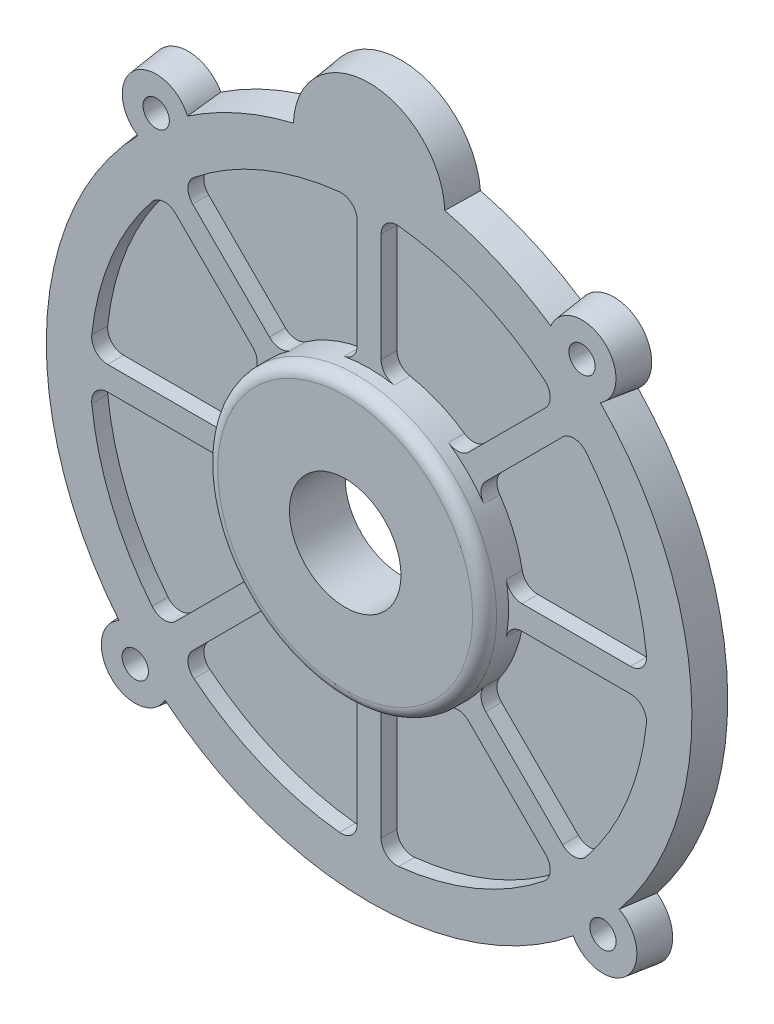
from build123d import *

# Parameters (mm, degrees)
BOSS_EXTRUDE1_START        = -4
BOSS_EXTRUDE1_DEPTH        = 4
BOSS_EXTRUDE1_DRAFT        = 7
CUT_EXTRUDE1_DEPTH         = 2
FILLET1_R                  = 2
CIRPATTERN1_COUNT          = 8
FILLET1_OF_CIRPATTERN1_R   = 2
M4X0_7_TAPPED_HOLE1_D      = 3.3
SKETCH9_R                  = 17.5
BOSS_EXTRUDE2_DEPTH        = 3
FILLET2_R                  = 1.5
F_14_0_14_DIAMETER_HOLE1_D = 14


with BuildPart() as part:
    # Sketch2 → Boss-Extrude1 (with draft: the straight prism first)
    with BuildSketch(Plane.XY.offset(BOSS_EXTRUDE1_START)):
        with BuildLine():
            ThreePointArc((-22.599988577, 34.208778352), (-29.7710089, 35.479706812), (-29.76462331, 28.19693599))
            ThreePointArc((-29.76462331, 28.19693599), (-40.960735586, 1.79391757), (-32.115758696, -25.486820975))
            ThreePointArc((-32.115758696, -25.486820975), (-32.70368863, -32.70368863), (-25.486820975, -32.115758696))
            ThreePointArc((-25.486820975, -32.115758696), (0, -41), (25.486820975, -32.115758696))
            ThreePointArc((25.486820975, -32.115758696), (32.70368863, -32.70368863), (32.115758696, -25.486820975))
            ThreePointArc((32.115758696, -25.486820975), (40.960735586, 1.79391757), (29.76462331, 28.19693599))
            ThreePointArc((29.76462331, 28.19693599), (29.7710089, 35.479706812), (22.599988577, 34.208778352))
            ThreePointArc((22.599988577, 34.208778352), (16.520796809, 37.524169182), (9.970370305, 39.769230769))
            ThreePointArc((9.970370305, 39.769230769), (0, 49), (-9.970370305, 39.769230769))
            ThreePointArc((-9.970370305, 39.769230769), (-16.520796809, 37.524169182), (-22.599988577, 34.208778352))
        make_face()
    extrude(amount=BOSS_EXTRUDE1_DEPTH)
    # Boss-Extrude1: the draft: its side faces are tilted about the plane it starts from
    boss_extrude1_sides = [part.faces().sort_by_distance(p)[0] for p in [
        (-16.520796809, 37.524169182, -2),
        (-29.7710089, 35.479706812, -2),
        (-40.960735586, 1.79391757, -2),
        (-32.70368863, -32.70368863, -2),
        (0, -41, -2),
        (32.70368863, -32.70368863, -2),
        (40.960735586, 1.79391757, -2),
        (29.7710089, 35.479706812, -2),
        (16.520796809, 37.524169182, -2),
        (0, 49, -2),
    ]]
    draft(boss_extrude1_sides, Plane.XY.offset(BOSS_EXTRUDE1_START), BOSS_EXTRUDE1_DRAFT)

    # Sketch4 → Cut-Extrude1 (cut)
    with BuildSketch(Plane.XY):
        with BuildLine():
            Line((-13.389488178, -11.268167834), (-25.786658635, -23.665338291))
            ThreePointArc((-25.786658635, -23.665338291), (-32.335783638, -13.393920133), (-34.96784237, -1.5))
            Line((-34.96784237, -1.5), (-17.435595774, -1.5))
            ThreePointArc((-17.435595774, -1.5), (-16.167891819, -6.696960066), (-13.389488178, -11.268167834))
        make_face()
    cut_extrude1 = extrude(amount=-CUT_EXTRUDE1_DEPTH, mode=Mode.SUBTRACT)

    # Fillet1
    fillet1_edges = [part.edges().sort_by_distance(p)[0] for p in [
        (-17.435595774, -1.5, -1),
        (-13.389488178, -11.268167834, -1),
        (-25.786658635, -23.665338291, -1),
        (-34.96784237, -1.5, -1),
    ]]
    fillet(fillet1_edges, radius=FILLET1_R)

    # CirPattern1: Cut-Extrude1 ×8 about axis
    cirpattern1_axis = Axis((0, 0, 0), (0, 0, 1))
    for i in range(1, CIRPATTERN1_COUNT):
        add(cut_extrude1.rotate(cirpattern1_axis, i * 360 / CIRPATTERN1_COUNT), mode=Mode.SUBTRACT)

    # Fillet1 of CirPattern1
    fillet1_of_cirpattern1_edges = [part.edges().sort_by_distance(p)[0] for p in [
        (-11.268167834, -13.389488178, -1),
        (-1.5, -17.435595774, -1),
        (-1.5, -34.96784237, -1),
        (-23.665338291, -25.786658635, -1),
        (1.5, -17.435595774, -1),
        (11.268167834, -13.389488178, -1),
        (23.665338291, -25.786658635, -1),
        (1.5, -34.96784237, -1),
        (13.389488178, -11.268167834, -1),
        (17.435595774, -1.5, -1),
        (34.96784237, -1.5, -1),
        (25.786658635, -23.665338291, -1),
        (17.435595774, 1.5, -1),
        (13.389488178, 11.268167834, -1),
        (25.786658635, 23.665338291, -1),
        (34.96784237, 1.5, -1),
        (11.268167834, 13.389488178, -1),
        (1.5, 17.435595774, -1),
        (1.5, 34.96784237, -1),
        (23.665338291, 25.786658635, -1),
        (-1.5, 17.435595774, -1),
        (-11.268167834, 13.389488178, -1),
        (-23.665338291, 25.786658635, -1),
        (-1.5, 34.96784237, -1),
        (-13.389488178, 11.268167834, -1),
        (-17.435595774, 1.5, -1),
        (-34.96784237, 1.5, -1),
        (-25.786658635, 23.665338291, -1),
    ]]
    fillet(fillet1_of_cirpattern1_edges, radius=FILLET1_OF_CIRPATTERN1_R)

    # M4x0.7 Tapped Hole1 (through all)
    with Locations(Plane(origin=(0, 0, -4), x_dir=(-1, 0, 0), z_dir=(0, 0, -1))):
        with Locations((26.717767754, 31.840995707), (29.344931419, -29.344931419), (-29.344931419, -29.344931419), (-26.717767754, 31.840995707)):
            Hole(M4X0_7_TAPPED_HOLE1_D / 2)

    # Sketch9 → Boss-Extrude2 (add)
    with BuildSketch(Plane.XY):
        Circle(SKETCH9_R)
    extrude(amount=BOSS_EXTRUDE2_DEPTH)

    # Fillet2
    fillet2_edges = [part.edges().sort_by_distance(p)[0] for p in [
        (-17.5, 0, 3),
    ]]
    fillet(fillet2_edges, radius=FILLET2_R)

    # Ø14.0 (14) Diameter Hole1 (through all)
    with Locations(Plane.XY.offset(3)):
        with Locations((0, 0)):
            Hole(F_14_0_14_DIAMETER_HOLE1_D / 2)


solid = part.part
